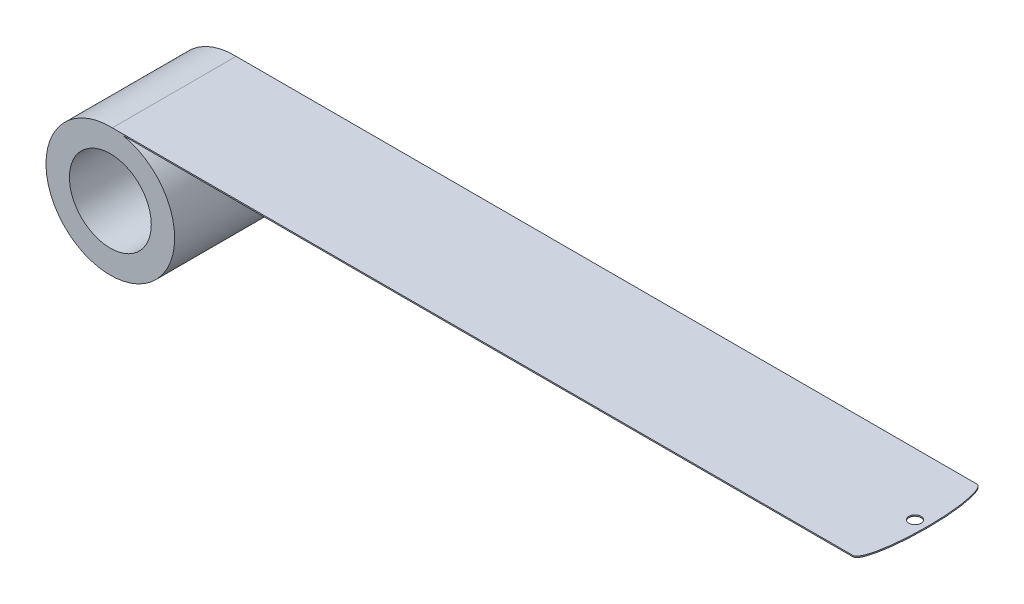
from build123d import *

# Parameters (mm, degrees)
SKETCH1_R           = 26.4033
SKETCH1_R_2         = 16.8021
BOSS_EXTRUDE1_DEPTH = 50.8
SKETCH2_R           = 2.4892
BOSS_EXTRUDE2_DEPTH = 0.508


with BuildPart() as part:
    # Sketch1 → Boss-Extrude1 (new body)
    with BuildSketch(Plane.XY):
        Circle(SKETCH1_R)
        Circle(SKETCH1_R_2, mode=Mode.SUBTRACT)
    extrude(amount=BOSS_EXTRUDE1_DEPTH)

    # Sketch2 → Boss-Extrude2 (add)
    with BuildSketch(Plane(origin=(0, 25.8826, 0), x_dir=(1, 0, 0), z_dir=(0, 1, 0))):
        with BuildLine():
            Line((0, -50.8), (0, 0))
            Line((0, 0), (304.8, 0))
            add(Edge.make_bspline(
                [(304.8, -50.8), (309.760765967, -50.8), (309.760765967, -25.4), (309.760765967, 0), (304.8, 0)],
                knots=[3.141592654, 3.141592654, 3.141592654, 4.71238898, 4.71238898, 6.283185307, 6.283185307, 6.283185307], degree=2, weights=[1, 0.707106781, 1, 0.707106781, 1]))
            Line((304.8, -50.8), (0, -50.8))
        make_face()
        with Locations((304.8, -25.4)):
            Circle(SKETCH2_R, mode=Mode.SUBTRACT)
    extrude(amount=BOSS_EXTRUDE2_DEPTH)


solid = part.part
